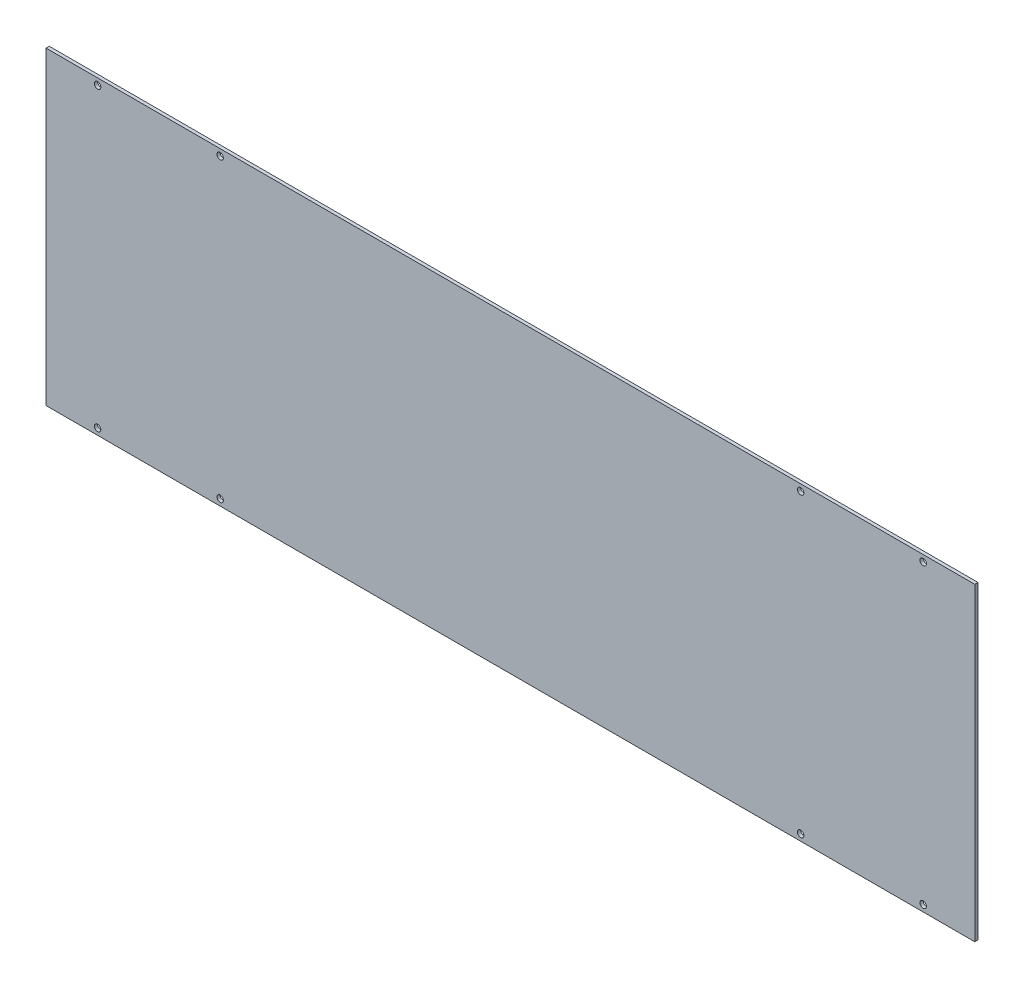
from build123d import *

# Parameters (mm, degrees)
SKETCH1_W                   = 914.4
SKETCH1_H                   = 304.8
BOSS_EXTRUDE1_DEPTH         = 3.175
F_1_4_0_25_DIAMETER_HOLE1_D = 6.35


with BuildPart() as part:
    # Sketch1 → Boss-Extrude1 (new body)
    with BuildSketch(Plane.XY):
        Rectangle(SKETCH1_W, SKETCH1_H)
    extrude(amount=BOSS_EXTRUDE1_DEPTH)

    # 1/4 (0.25) Diameter Hole1 (through all)
    with Locations(Plane.XY.offset(3.175)):
        with Locations((285.75, 146.05), (406.4, 146.05), (406.4, -146.05), (285.75, -146.05)):
            f_1_4_0_25_diameter_hole1 = Hole(F_1_4_0_25_DIAMETER_HOLE1_D / 2)

    # Mirror1: 1/4 (0.25) Diameter Hole1 across plane
    add(f_1_4_0_25_diameter_hole1.mirror(Plane(origin=(0, 0, 0), x_dir=(0, 0, 1), z_dir=(1, 0, 0))), mode=Mode.SUBTRACT)


solid = part.part
